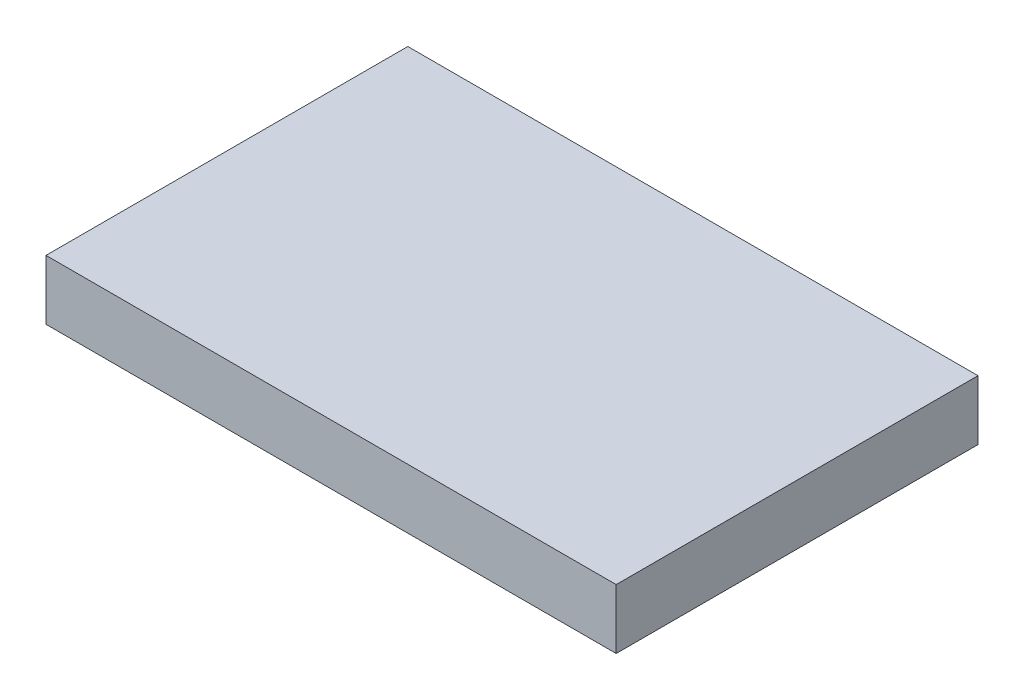
from build123d import *

# Parameters (mm, degrees)
CROQUIS1_W              = 2864.93
CROQUIS1_H              = 300
SALIENTE_EXTRUIR1_DEPTH = 1817.97


with BuildPart() as part:
    # Croquis1 → Saliente-Extruir1 (new body)
    with BuildSketch(Plane.XY):
        with Locations((195.34780545, 423.71684949)):
            Rectangle(CROQUIS1_W, CROQUIS1_H)
    extrude(amount=SALIENTE_EXTRUIR1_DEPTH)


solid = part.part
